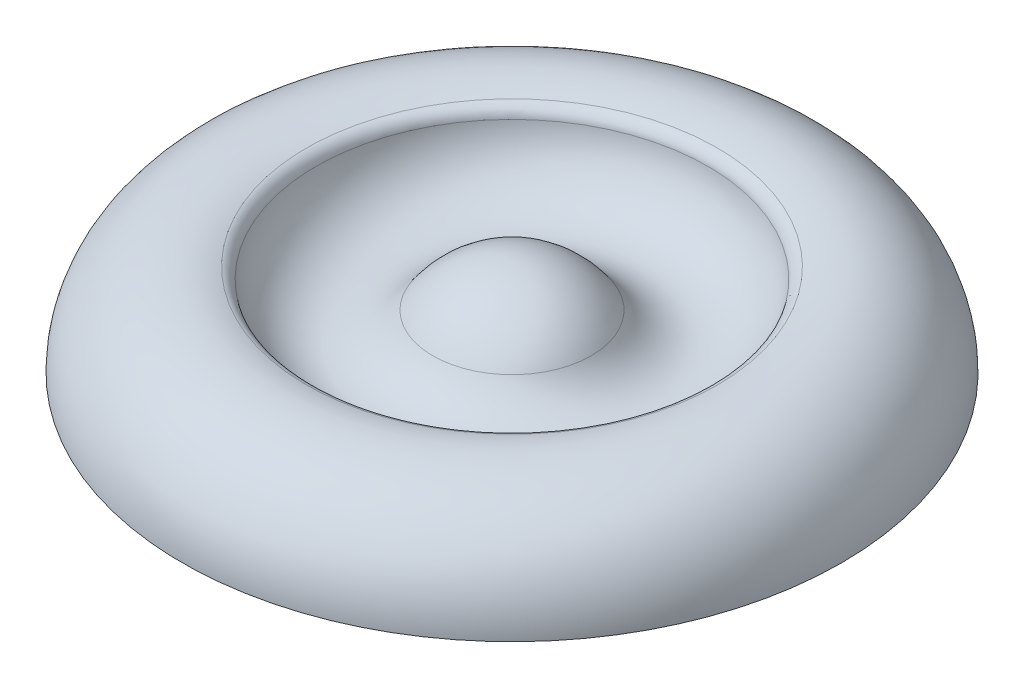
from build123d import *


with BuildPart() as part:
    # Sketch1 → Revolve1 (revolve)
    with BuildSketch(Plane.XY):
        with BuildLine():
            Line((0, 0), (76.2, 0))
            ThreePointArc((76.2, 0), (67.199615798, 17.862255232), (47.4881744, 21.257274487))
            ThreePointArc((47.4881744, 21.257274487), (46.012525152, 20.296429021), (45.275826794, 18.697041563))
            ThreePointArc((45.275826794, 18.697041563), (33.897077144, 6.443095124), (18.324879741, 12.537503622))
            ThreePointArc((18.324879741, 12.537503622), (10.358938662, 19.638803537), (0, 22.203382953))
            Line((0, 22.203382953), (0, 0))
        make_face()
    revolve(axis=Axis((0, 0, 0), (0, 1, 0)))


solid = part.part
